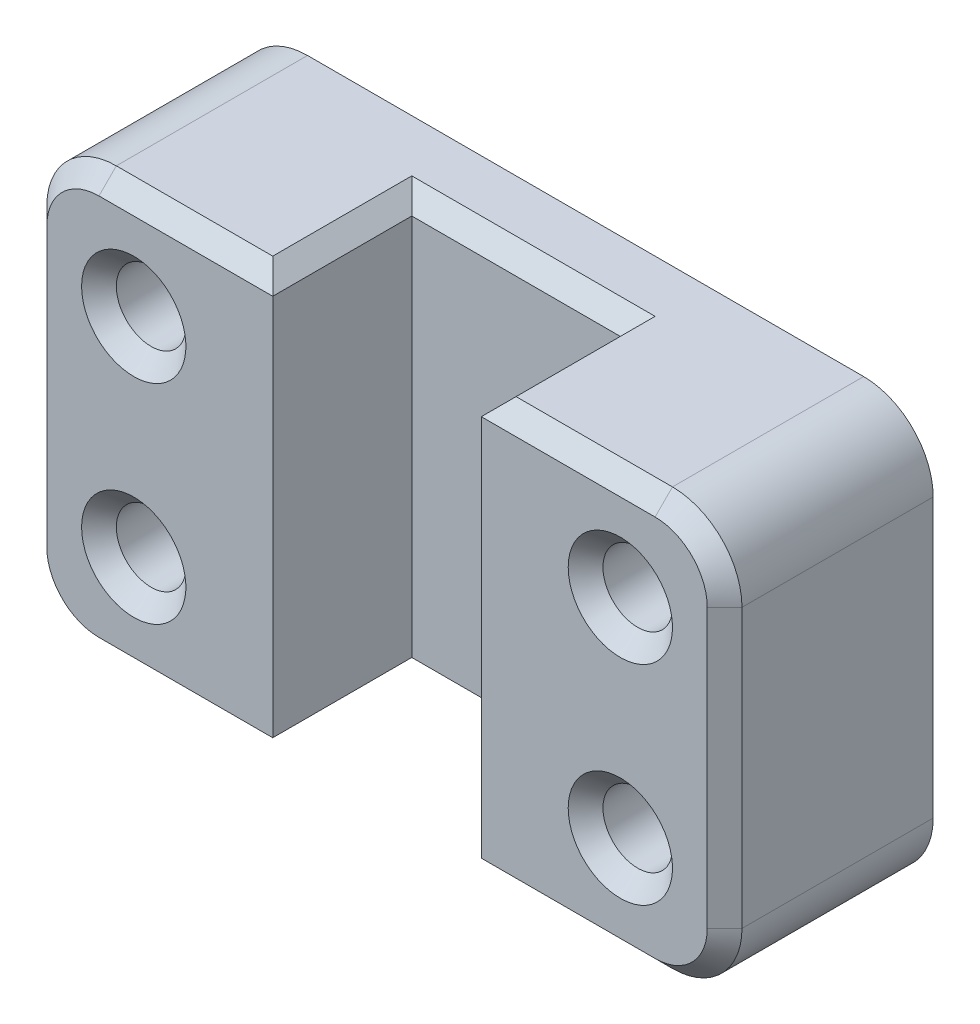
from build123d import *

# Parameters (mm, degrees)
SKETCH1_W           = 127
SKETCH1_H           = 76.2
SKETCH1_R           = 6.35
BOSS_EXTRUDE1_DEPTH = 38.1
SKETCH3_W           = 38.1
SKETCH3_H           = 76.2
CUT_EXTRUDE1_DEPTH  = 25.4
FILLET1_R           = 12.7
CHAMFER1_SIZE       = 3.175
SHELL1_T            = -2.54


with BuildPart() as part:
    # Sketch1 → Boss-Extrude1 (new body)
    with BuildSketch(Plane.XY):
        Rectangle(SKETCH1_W, SKETCH1_H)
        with Locations((-44.45, 19.05)):
            Circle(SKETCH1_R, mode=Mode.SUBTRACT)
        with Locations((44.45, 19.05)):
            Circle(SKETCH1_R, mode=Mode.SUBTRACT)
        with Locations((-44.45, -19.05)):
            Circle(SKETCH1_R, mode=Mode.SUBTRACT)
        with Locations((44.45, -19.05)):
            Circle(SKETCH1_R, mode=Mode.SUBTRACT)
    extrude(amount=BOSS_EXTRUDE1_DEPTH)

    # Sketch3 → Cut-Extrude1 (cut)
    with BuildSketch(Plane.XY.offset(38.1)):
        Rectangle(SKETCH3_W, SKETCH3_H)
    extrude(amount=-CUT_EXTRUDE1_DEPTH, mode=Mode.SUBTRACT)

    # Fillet1
    fillet1_edges = [part.edges().sort_by_distance(p)[0] for p in [
        (63.5, -38.1, 19.05),
        (-63.5, -38.1, 19.05),
        (-63.5, 38.1, 19.05),
        (63.5, 38.1, 19.05),
    ]]
    fillet(fillet1_edges, radius=FILLET1_R)

    # Chamfer1
    chamfer1_edges = [part.edges().sort_by_distance(p)[0] for p in [
        (-50.8, 19.05, 38.1),
        (38.1, 19.05, 38.1),
        (-50.8, -19.05, 38.1),
        (38.1, -19.05, 38.1),
        (34.925, -38.1, 38.1),
        (-34.925, 38.1, 38.1),
        (19.05, 38.1, 25.4),
        (0, -38.1, 12.7),
        (19.05, -38.1, 25.4),
        (-19.05, -38.1, 25.4),
        (0, 38.1, 12.7),
        (-19.05, 38.1, 25.4),
        (-34.925, -38.1, 38.1),
        (-63.5, 0, 38.1),
        (-59.780256121, 34.380256121, 38.1),
        (-59.780256121, -34.380256121, 38.1),
        (63.5, 0, 38.1),
        (34.925, 38.1, 38.1),
        (59.780256121, 34.380256121, 38.1),
        (59.780256121, -34.380256121, 38.1),
    ]]
    chamfer(chamfer1_edges, length=CHAMFER1_SIZE)

    # Shell1
    shell1_openings = [part.faces().sort_by_distance(p)[0] for p in [
        (-50.8, -19.05, 0),
    ]]
    offset(amount=SHELL1_T, openings=shell1_openings, kind=Kind.INTERSECTION)


solid = part.part
